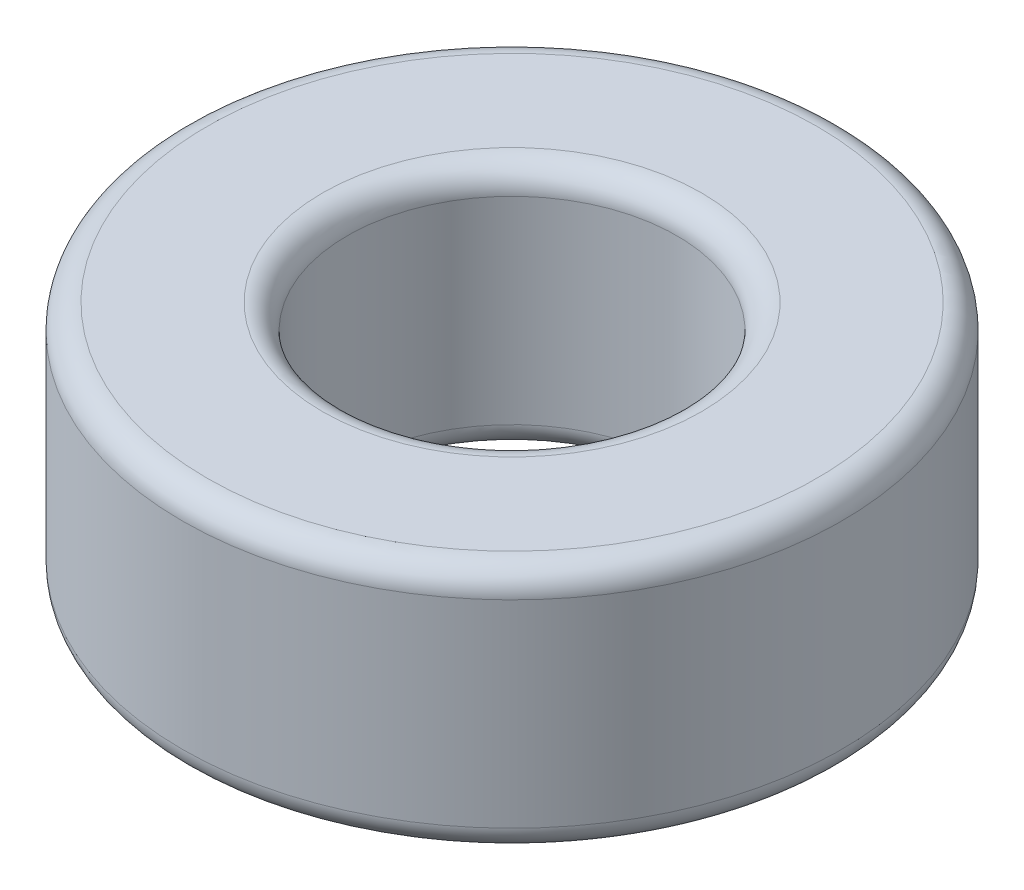
from build123d import *

# Parameters (mm, degrees)
SKETCH1_R   = 6.35
SKETCH1_R_2 = 3.175
BORE_DEPTH  = 4.7625
FILLET_2_R  = 0.47625


with BuildPart() as part:
    # Sketch1 → Bore (new body)
    with BuildSketch(Plane(origin=(0, 0, 0), x_dir=(1, 0, 0), z_dir=(0, 1, 0))):
        Circle(SKETCH1_R)
        Circle(SKETCH1_R_2, mode=Mode.SUBTRACT)
    extrude(amount=BORE_DEPTH)

    # Fillet 2
    fillet_2_edges = [part.edges().sort_by_distance(p)[0] for p in [
        (-6.35, 0, 0),
        (-6.35, 4.7625, 0),
        (-3.175, 0, 0),
        (-3.175, 4.7625, 0),
    ]]
    fillet(fillet_2_edges, radius=FILLET_2_R)


solid = part.part
